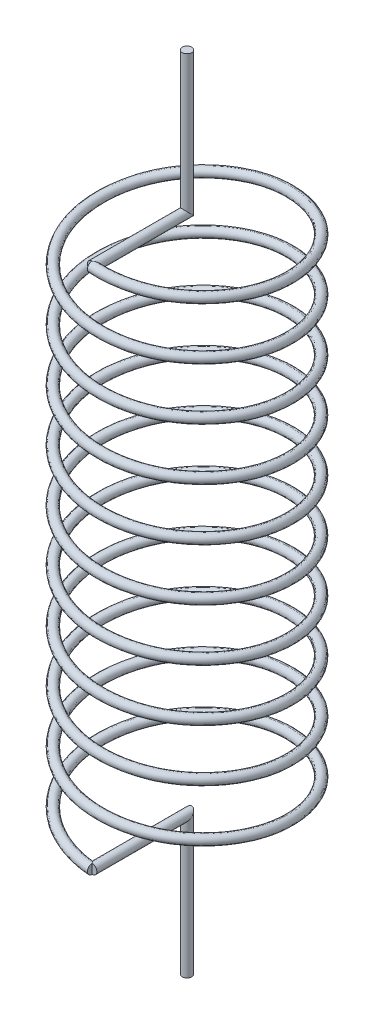
from build123d import *

# Parameters (mm, degrees)
SWEEP1_PITCH  = 1.1
SWEEP1_HEIGHT = 11
SWEEP1_RADIUS = 2
SKETCH2_R     = 0.1
SKETCH5_R     = 0.1
SKETCH7_R     = 0.1


with BuildPart() as part:
    # Sweep1: sweep along a helix
    with BuildLine() as sweep1_path:
        Helix(SWEEP1_PITCH, SWEEP1_HEIGHT, SWEEP1_RADIUS, center=(0, 0, 0), direction=(0, 1, 0), lefthand=True)
    # Sketch2 → Sweep1 (sweep)
    with BuildSketch(Plane(origin=(0, 0, 0), x_dir=(0, 0, -1), z_dir=(1, 0, 0))):
        with Locations((-2, 0)):
            Circle(SKETCH2_R)
    sweep(path=sweep1_path.line, is_frenet=True)

    # Sweep2: sweep along a path in Sketch4
    with BuildLine(Plane(origin=(0, 0, 0), x_dir=(0, 0, -1), z_dir=(1, 0, 0))) as sweep2_path:
        Line((-2, 0), (0, 0))
        Line((0, 0), (0, -2.921124617))
    # Sketch5 → Sweep2 (sweep)
    with BuildSketch(Plane(origin=(0, -2.921124617, 0), x_dir=(1, 0, 0), z_dir=(0, 1, 0))):
        Circle(SKETCH5_R)
    sweep(path=sweep2_path.line, transition=Transition.RIGHT)

    # Sweep3: sweep along a path in Sketch6
    with BuildLine(Plane(origin=(0, 0, 0), x_dir=(0, 0, -1), z_dir=(1, 0, 0))) as sweep3_path:
        Line((-2, 11), (0, 11))
        Line((0, 11), (0, 13.954009385))
    # Sketch7 → Sweep3 (sweep)
    with BuildSketch(Plane(origin=(0, 13.954009385, 0), x_dir=(1, 0, 0), z_dir=(0, 1, 0))):
        Circle(SKETCH7_R)
    sweep(path=sweep3_path.line, transition=Transition.RIGHT)


solid = part.part
